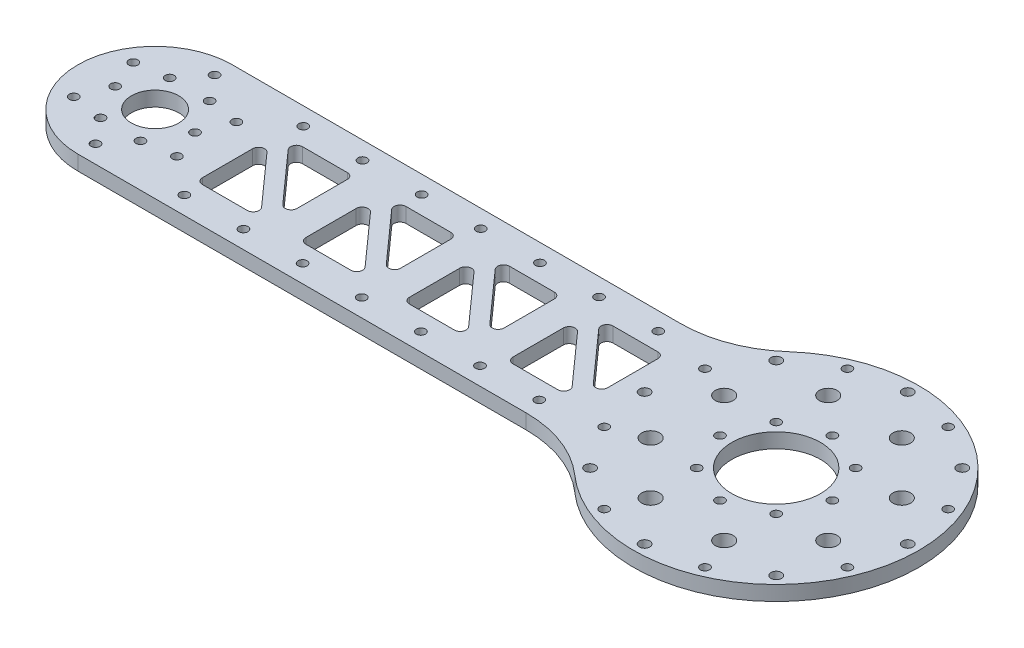
from build123d import *

# Parameters (mm, degrees)
EXTRUDE_1_DEPTH      = 5
SKETCH_2_R           = 1.525
CUT_EXTRUDE_1_DEPTH  = 6
SKETCH_3_R           = 48.25
EXTRUDE_2_DEPTH      = 5
SKETCH_6_R           = 1.525
CUT_EXTRUDE_4_DEPTH  = 6
SKETCH_7_R           = 1.775
CUT_EXTRUDE_5_DEPTH  = 6
FILLET_1_R           = 40
SKETCH_9_R           = 14
CUT_EXTRUDE_7_DEPTH  = 6
SKETCH_10_R          = 8
CUT_EXTRUDE_8_DEPTH  = 6
SKETCH_11_R          = 15
CUT_EXTRUDE_9_DEPTH  = 6
SKETCH_12_R          = 3
CUT_EXTRUDE_10_DEPTH = 6
SKETCH_13_R          = 1.525
CUT_EXTRUDE_11_DEPTH = 6
SKETCH_18_R          = 1.525
CUT_EXTRUDE_13_DEPTH = 6
SKETCH_21_R          = 1.525
CUT_EXTRUDE_15_DEPTH = 6
CUT_EXTRUDE_16_DEPTH = 6


with BuildPart() as part:
    # 草图1 → 凸台-拉伸1 (new body)
    with BuildSketch(Plane(origin=(0, 0, 0), x_dir=(1, 0, 0), z_dir=(0, 1, 0))):
        with BuildLine():
            ThreePointArc((-78.875, 0), (-86.526835342, -18.473164658), (-105, -26.125))
            Line((-105, -26.125), (105, -26.125))
            Line((105, -26.125), (105, 26.125))
            Line((105, 26.125), (-105, 26.125))
            ThreePointArc((-105, 26.125), (-86.526835342, 18.473164658), (-78.875, 0))
        make_face()
        with BuildLine():
            ThreePointArc((-105, 26.125), (-131.125, 0), (-105, -26.125))
            Line((-105, -26.125), (-105, 26.125))
        make_face()
        with BuildLine():
            Line((-105, 26.125), (-105, -26.125))
            ThreePointArc((-105, -26.125), (-86.526835342, -18.473164658), (-78.875, 0))
            ThreePointArc((-78.875, 0), (-86.526835342, 18.473164658), (-105, 26.125))
        make_face()
    extrude(amount=EXTRUDE_1_DEPTH)

    # 草图2 → 切除-拉伸1 (cut, through all)
    with BuildSketch(Plane(origin=(0, 5, 0), x_dir=(1, 0, 0), z_dir=(0, 1, 0))):
        with Locations((-91.5, 0)):
            Circle(SKETCH_2_R)
        with Locations((-98.25, -11.691342951)):
            Circle(SKETCH_2_R)
        with Locations((-111.75, -11.691342951)):
            Circle(SKETCH_2_R)
        with Locations((-118.5, 0)):
            Circle(SKETCH_2_R)
        with Locations((-111.75, 11.691342951)):
            Circle(SKETCH_2_R)
        with Locations((-98.25, 11.691342951)):
            Circle(SKETCH_2_R)
    extrude(amount=-CUT_EXTRUDE_1_DEPTH, mode=Mode.SUBTRACT)

    # 草图3 → 凸台-拉伸2 (add)
    with BuildSketch(Plane(origin=(0, 5, 0), x_dir=(1, 0, 0), z_dir=(0, 1, 0))):
        with Locations((105, 0)):
            Circle(SKETCH_3_R)
    extrude(amount=-EXTRUDE_2_DEPTH)

    # 草图6 → 切除-拉伸4 (cut, through all)
    with BuildSketch(Plane(origin=(0, 5, 0), x_dir=(1, 0, 0), z_dir=(0, 1, 0))):
        with Locations((118.435028843, 13.435028843)):
            Circle(SKETCH_6_R)
        with Locations((124, 0)):
            Circle(SKETCH_6_R)
        with Locations((118.435028843, -13.435028843)):
            Circle(SKETCH_6_R)
        with Locations((105, -19)):
            Circle(SKETCH_6_R)
        with Locations((91.564971157, -13.435028843)):
            Circle(SKETCH_6_R)
        with Locations((86, 0)):
            Circle(SKETCH_6_R)
        with Locations((91.564971157, 13.435028843)):
            Circle(SKETCH_6_R)
        with Locations((105, 19)):
            Circle(SKETCH_6_R)
    extrude(amount=-CUT_EXTRUDE_4_DEPTH, mode=Mode.SUBTRACT)

    # 草图7 → 切除-拉伸5 (cut, through all)
    with BuildSketch(Plane(origin=(0, 5, 0), x_dir=(1, 0, 0), z_dir=(0, 1, 0))):
        with Locations((149.5, 0)):
            Circle(SKETCH_7_R)
        with Locations((136.466251763, -31.466251763)):
            Circle(SKETCH_7_R)
        with Locations((105, -44.5)):
            Circle(SKETCH_7_R)
        with Locations((73.533748237, -31.466251763)):
            Circle(SKETCH_7_R)
        with Locations((60.5, 0)):
            Circle(SKETCH_7_R)
        with Locations((73.533748237, 31.466251763)):
            Circle(SKETCH_7_R)
        with Locations((105, 44.5)):
            Circle(SKETCH_7_R)
        with Locations((136.466251763, 31.466251763)):
            Circle(SKETCH_7_R)
    extrude(amount=-CUT_EXTRUDE_5_DEPTH, mode=Mode.SUBTRACT)

    # 圆角1
    fillet_1_edges = [part.edges().sort_by_distance(p)[0] for p in [
        (64.43465919, 2.5, 26.125),
        (64.43465919, 2.5, -26.125),
    ]]
    fillet(fillet_1_edges, radius=FILLET_1_R)

    # 草图9 → 切除-拉伸7 (cut, through all)
    with BuildSketch(Plane(origin=(0, 5, 0), x_dir=(1, 0, 0), z_dir=(0, 1, 0))):
        with Locations((105, 0)):
            Circle(SKETCH_9_R)
    extrude(amount=-CUT_EXTRUDE_7_DEPTH, mode=Mode.SUBTRACT)

    # 草图10 → 切除-拉伸8 (cut, through all)
    with BuildSketch(Plane(origin=(0, 5, 0), x_dir=(1, 0, 0), z_dir=(0, 1, 0))):
        with Locations((-105, 0)):
            Circle(SKETCH_10_R)
    extrude(amount=-CUT_EXTRUDE_8_DEPTH, mode=Mode.SUBTRACT)

    # 草图11 → 切除-拉伸9 (cut, through all)
    with BuildSketch(Plane(origin=(0, 5, 0), x_dir=(1, 0, 0), z_dir=(0, 1, 0))):
        with Locations((105, 0)):
            Circle(SKETCH_11_R)
    extrude(amount=-CUT_EXTRUDE_9_DEPTH, mode=Mode.SUBTRACT)

    # 草图12 → 切除-拉伸10 (cut, through all)
    with BuildSketch(Plane(origin=(0, 5, 0), x_dir=(1, 0, 0), z_dir=(0, 1, 0))):
        with Locations((117.437211552, 30.026084807)):
            Circle(SKETCH_12_R)
        with Locations((135.026084807, 12.437211552)):
            Circle(SKETCH_12_R)
        with Locations((135.026084807, -12.437211552)):
            Circle(SKETCH_12_R)
        with Locations((117.437211552, -30.026084807)):
            Circle(SKETCH_12_R)
        with Locations((92.562788448, -30.026084807)):
            Circle(SKETCH_12_R)
        with Locations((74.973915193, -12.437211552)):
            Circle(SKETCH_12_R)
        with Locations((74.973915193, 12.437211552)):
            Circle(SKETCH_12_R)
        with Locations((92.562788448, 30.026084807)):
            Circle(SKETCH_12_R)
    extrude(amount=-CUT_EXTRUDE_10_DEPTH, mode=Mode.SUBTRACT)

    # 草图13 → 切除-拉伸11 (cut, through all)
    with BuildSketch(Plane(origin=(0, 5, 0), x_dir=(1, 0, 0), z_dir=(0, 1, 0))):
        with Locations((122.02941274, 41.112639197)):
            Circle(SKETCH_13_R)
        with Locations((146.112639197, 17.02941274)):
            Circle(SKETCH_13_R)
        with Locations((146.112639197, -17.02941274)):
            Circle(SKETCH_13_R)
        with Locations((122.02941274, -41.112639197)):
            Circle(SKETCH_13_R)
        with Locations((87.97058726, -41.112639197)):
            Circle(SKETCH_13_R)
        with Locations((63.887360803, -17.02941274)):
            Circle(SKETCH_13_R)
        with Locations((63.887360803, 17.02941274)):
            Circle(SKETCH_13_R)
        with Locations((87.97058726, 41.112639197)):
            Circle(SKETCH_13_R)
    extrude(amount=-CUT_EXTRUDE_11_DEPTH, mode=Mode.SUBTRACT)

    # 草图18 → 切除-拉伸13 (cut, through all)
    with BuildSketch(Plane(origin=(0, 5, 0), x_dir=(1, 0, 0), z_dir=(0, 1, 0))):
        with Locations((45, 20.125)):
            Circle(SKETCH_18_R)
        with Locations((25, 20.125)):
            Circle(SKETCH_18_R)
        with Locations((5, 20.125)):
            Circle(SKETCH_18_R)
        with Locations((-15, 20.125)):
            Circle(SKETCH_18_R)
        with Locations((-35, 20.125)):
            Circle(SKETCH_18_R)
        with Locations((-55, 20.125)):
            Circle(SKETCH_18_R)
        with Locations((-75, 20.125)):
            Circle(SKETCH_18_R)
    cut_extrude_13 = extrude(amount=-CUT_EXTRUDE_13_DEPTH, mode=Mode.SUBTRACT)

    # 镜向2: 切除-拉伸13 across plane
    add(cut_extrude_13.mirror(Plane.XY), mode=Mode.SUBTRACT)

    # 草图21 → 切除-拉伸15 (cut, through all)
    with BuildSketch(Plane(origin=(0, 5, 0), x_dir=(1, 0, 0), z_dir=(0, 1, 0))):
        with Locations((-105, 20.125)):
            Circle(SKETCH_21_R)
        with Locations((-87.571238749, 10.0625)):
            Circle(SKETCH_21_R)
        with Locations((-87.571238749, -10.0625)):
            Circle(SKETCH_21_R)
        with Locations((-105, -20.125)):
            Circle(SKETCH_21_R)
        with Locations((-122.428761251, -10.0625)):
            Circle(SKETCH_21_R)
        with Locations((-122.428761251, 10.0625)):
            Circle(SKETCH_21_R)
    extrude(amount=-CUT_EXTRUDE_15_DEPTH, mode=Mode.SUBTRACT)

    # 草图22 → 切除-拉伸16 (cut, through all)
    with BuildSketch(Plane.XZ):
        with BuildLine():
            Line((-69.181610021, -14), (-54, -14))
            ThreePointArc((-54, -14), (-52.585786438, -13.414213562), (-52, -12))
            Line((-52, -12), (-52, 5.003403224))
            ThreePointArc((-52, 5.003403224), (-53.287171355, 6.872059244), (-55.491875323, 6.335434762))
            Line((-55.491875323, 6.335434762), (-70.673485344, -10.667968461))
            ThreePointArc((-70.673485344, -10.667968461), (-71.006995333, -12.817293375), (-69.181610021, -14))
        make_face()
        with BuildLine():
            Line((-73.508124677, -6.335434762), (-58.326514656, 10.667968461))
            ThreePointArc((-58.326514656, 10.667968461), (-57.993004667, 12.817293375), (-59.818389979, 14))
            Line((-59.818389979, 14), (-75, 14))
            ThreePointArc((-75, 14), (-76.414213562, 13.414213562), (-77, 12))
            Line((-77, 12), (-77, -5.003403224))
            ThreePointArc((-77, -5.003403224), (-75.712828645, -6.872059244), (-73.508124677, -6.335434762))
        make_face()
        with BuildLine():
            Line((-42, 12), (-42, -5.003403224))
            ThreePointArc((-42, -5.003403224), (-40.712828645, -6.872059244), (-38.508124677, -6.335434762))
            Line((-38.508124677, -6.335434762), (-23.326514656, 10.667968461))
            ThreePointArc((-23.326514656, 10.667968461), (-22.993004667, 12.817293375), (-24.818389979, 14))
            Line((-24.818389979, 14), (-40, 14))
            ThreePointArc((-40, 14), (-41.414213562, 13.414213562), (-42, 12))
        make_face()
        with BuildLine():
            Line((-34.181610021, -14), (-19, -14))
            ThreePointArc((-19, -14), (-17.585786438, -13.414213562), (-17, -12))
            Line((-17, -12), (-17, 5.003403224))
            ThreePointArc((-17, 5.003403224), (-18.287171355, 6.872059244), (-20.491875323, 6.335434762))
            Line((-20.491875323, 6.335434762), (-35.673485344, -10.667968461))
            ThreePointArc((-35.673485344, -10.667968461), (-36.006995333, -12.817293375), (-34.181610021, -14))
        make_face()
        with BuildLine():
            Line((-7, 12), (-7, -5.003403224))
            ThreePointArc((-7, -5.003403224), (-5.712828645, -6.872059244), (-3.508124677, -6.335434762))
            Line((-3.508124677, -6.335434762), (11.673485344, 10.667968461))
            ThreePointArc((11.673485344, 10.667968461), (12.006995333, 12.817293375), (10.181610021, 14))
            Line((10.181610021, 14), (-5, 14))
            ThreePointArc((-5, 14), (-6.414213562, 13.414213562), (-7, 12))
        make_face()
        with BuildLine():
            Line((0.818389979, -14), (16, -14))
            ThreePointArc((16, -14), (17.414213562, -13.414213562), (18, -12))
            Line((18, -12), (18, 5.003403224))
            ThreePointArc((18, 5.003403224), (16.712828645, 6.872059244), (14.508124677, 6.335434762))
            Line((14.508124677, 6.335434762), (-0.673485344, -10.667968461))
            ThreePointArc((-0.673485344, -10.667968461), (-1.006995333, -12.817293375), (0.818389979, -14))
        make_face()
        with BuildLine():
            Line((28, 12), (28, -5.003403224))
            ThreePointArc((28, -5.003403224), (29.287171355, -6.872059244), (31.491875323, -6.335434762))
            Line((31.491875323, -6.335434762), (46.673485344, 10.667968461))
            ThreePointArc((46.673485344, 10.667968461), (47.006995333, 12.817293375), (45.181610021, 14))
            Line((45.181610021, 14), (30, 14))
            ThreePointArc((30, 14), (28.585786438, 13.414213562), (28, 12))
        make_face()
        with BuildLine():
            Line((35.818389979, -14), (51, -14))
            ThreePointArc((51, -14), (52.414213562, -13.414213562), (53, -12))
            Line((53, -12), (53, 5.003403224))
            ThreePointArc((53, 5.003403224), (51.712828645, 6.872059244), (49.508124677, 6.335434762))
            Line((49.508124677, 6.335434762), (34.326514656, -10.667968461))
            ThreePointArc((34.326514656, -10.667968461), (33.993004667, -12.817293375), (35.818389979, -14))
        make_face()
    extrude(amount=-CUT_EXTRUDE_16_DEPTH, mode=Mode.SUBTRACT)


solid = part.part
